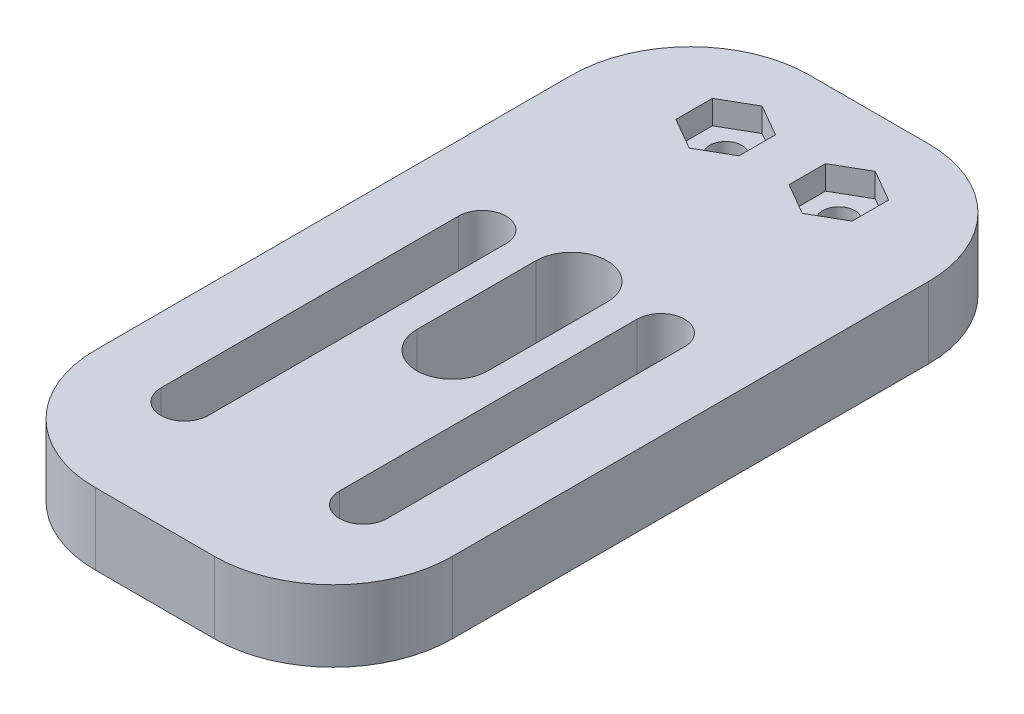
from build123d import *

# Parameters (mm, degrees)
CROQUIS2_W              = 30
CROQUIS2_H              = 60
SALIENTE_EXTRUIR1_DEPTH = 6
REDONDEO1_R             = 10
REDONDEO2_R             = 10
CROQUIS3_R              = 1.35
CORTAR_EXTRUIR1_DEPTH   = 7
CORTAR_EXTRUIR2_DEPTH   = 2


with BuildPart() as part:
    # Croquis2 → Saliente-Extruir1 (new body)
    with BuildSketch(Plane(origin=(0, 0, 0), x_dir=(1, 0, 0), z_dir=(0, 1, 0))):
        with Locations((0, 30)):
            Rectangle(CROQUIS2_W, CROQUIS2_H)
        with BuildLine():
            Line((-5.5, 35), (-5.5, 10))
            ThreePointArc((-5.5, 10), (-7.5, 8), (-9.5, 10))
            Line((-9.5, 10), (-9.5, 35))
            ThreePointArc((-9.5, 35), (-7.5, 37), (-5.5, 35))
        make_face(mode=Mode.SUBTRACT)
        with BuildLine():
            Line((9.5, 35), (9.5, 10))
            ThreePointArc((9.5, 10), (7.5, 8), (5.5, 10))
            Line((5.5, 10), (5.5, 35))
            ThreePointArc((5.5, 35), (7.5, 37), (9.5, 35))
        make_face(mode=Mode.SUBTRACT)
        with BuildLine():
            Line((3, 35), (3, 25))
            ThreePointArc((3, 25), (0, 22), (-3, 25))
            Line((-3, 25), (-3, 35))
            ThreePointArc((-3, 35), (0, 38), (3, 35))
        make_face(mode=Mode.SUBTRACT)
    extrude(amount=SALIENTE_EXTRUIR1_DEPTH)

    # Redondeo1
    redondeo1_edges = [part.edges().sort_by_distance(p)[0] for p in [
        (-15, 3, -60),
        (15, 3, -60),
    ]]
    fillet(redondeo1_edges, radius=REDONDEO1_R)

    # Redondeo2
    redondeo2_edges = [part.edges().sort_by_distance(p)[0] for p in [
        (15, 3, 0),
        (-15, 3, 0),
    ]]
    fillet(redondeo2_edges, radius=REDONDEO2_R)

    # Croquis3 → Cortar-Extruir1 (cut, through all)
    with BuildSketch(Plane.XZ):
        with Locations((4.75, -52.7)):
            Circle(CROQUIS3_R)
        with Locations((-4.75, -52.7)):
            Circle(CROQUIS3_R)
    extrude(amount=-CORTAR_EXTRUIR1_DEPTH, mode=Mode.SUBTRACT)

    # Croquis4 → Cortar-Extruir2 (cut)
    with BuildSketch(Plane(origin=(0, 6, 0), x_dir=(-1, 0, 0), z_dir=(0, -1, 0))):
        Polygon((-2.1, 51.170021787), (-2.1, 54.229978213), (-4.75, 55.759956427), (-7.4, 54.229978213), (-7.4, 51.170021787), (-4.75, 49.640043573), align=None)
        Polygon((7.4, 51.170021787), (7.4, 54.229978213), (4.75, 55.759956427), (2.1, 54.229978213), (2.1, 51.170021787), (4.75, 49.640043573), align=None)
    extrude(amount=CORTAR_EXTRUIR2_DEPTH, mode=Mode.SUBTRACT)


solid = part.part
